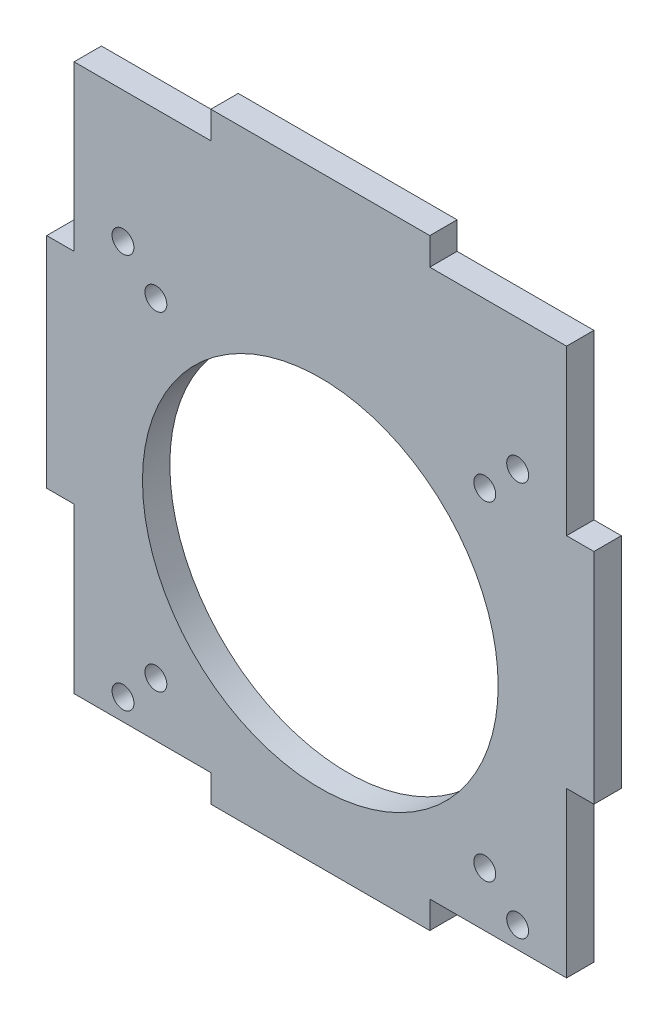
from build123d import *

# Parameters (mm, degrees)
SKETCH1_R           = 2
SKETCH1_R_2         = 32.5
BOSS_EXTRUDE1_DEPTH = 5


with BuildPart() as part:
    # Sketch1 → Boss-Extrude1 (new body)
    with BuildSketch(Plane.XY):
        Polygon((45, -40), (20, -40), (20, -45), (-20, -45), (-20, -40), (-45, -40), (-45, -10), (-50, -10), (-50, 30), (-45, 30), (-45, 60), (-20, 60), (-20, 65), (20, 65), (20, 60), (45, 60), (45, 30), (50, 30), (50, -10), (45, -10), align=None)
        with Locations((-36.06, 36.06)):
            Circle(SKETCH1_R, mode=Mode.SUBTRACT)
        with Locations((36.06, 36.06)):
            Circle(SKETCH1_R, mode=Mode.SUBTRACT)
        with Locations((36.06, -36.06)):
            Circle(SKETCH1_R, mode=Mode.SUBTRACT)
        with Locations((-36.06, -36.06)):
            Circle(SKETCH1_R, mode=Mode.SUBTRACT)
        Circle(SKETCH1_R_2, mode=Mode.SUBTRACT)
        with Locations((-30.0520382, 30.0520382)):
            Circle(SKETCH1_R, mode=Mode.SUBTRACT)
        with Locations((30.0520382, 30.0520382)):
            Circle(SKETCH1_R, mode=Mode.SUBTRACT)
        with Locations((30.0520382, -30.0520382)):
            Circle(SKETCH1_R, mode=Mode.SUBTRACT)
        with Locations((-30.0520382, -30.0520382)):
            Circle(SKETCH1_R, mode=Mode.SUBTRACT)
    extrude(amount=BOSS_EXTRUDE1_DEPTH)


solid = part.part
